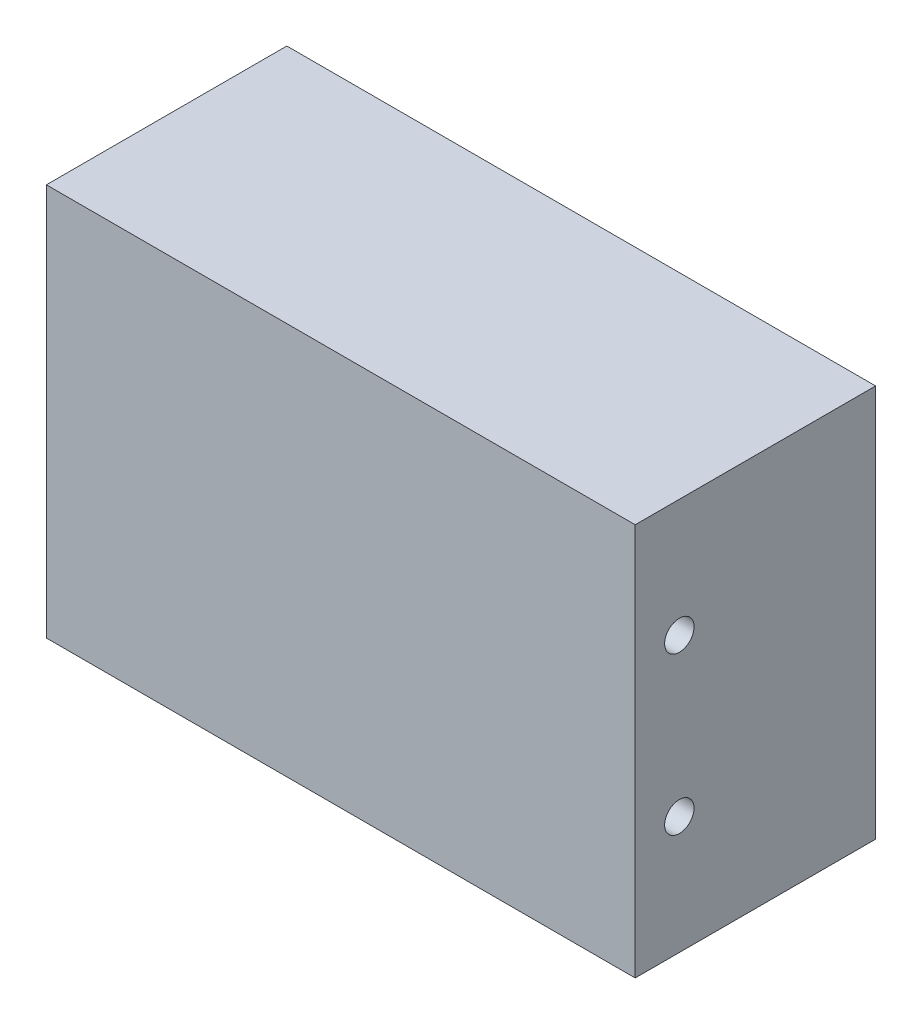
from build123d import *

# Parameters (mm, degrees)
SKETCH_1_W          = 60
SKETCH_1_H          = 24.5
EXTRUDE_1_DEPTH     = 40
SKETCH_2_R          = 1.5
CUT_EXTRUDE_1_DEPTH = 0.5
SKETCH_3_R          = 1.5
CUT_EXTRUDE_2_DEPTH = 3


with BuildPart() as part:
    # 草图1 → 凸台-拉伸1 (new body)
    with BuildSketch(Plane(origin=(0, 0, 0), x_dir=(1, 0, 0), z_dir=(0, 1, 0))):
        Rectangle(SKETCH_1_W, SKETCH_1_H)
    extrude(amount=EXTRUDE_1_DEPTH)

    # 草图2 → 切除-拉伸1 (cut)
    with BuildSketch(Plane(origin=(0, 0, 0), x_dir=(-1, 0, 0), z_dir=(0, -1, 0))):
        with Locations((8, -7.75)):
            Circle(SKETCH_2_R)
        with Locations((-8, -7.75)):
            Circle(SKETCH_2_R)
    extrude(amount=-CUT_EXTRUDE_1_DEPTH, mode=Mode.SUBTRACT)

    # 草图3 → 切除-拉伸2 (cut)
    with BuildSketch(Plane(origin=(30, 0, 0), x_dir=(0, 0, -1), z_dir=(1, 0, 0))):
        with Locations((-7.75, 28)):
            Circle(SKETCH_3_R)
        with Locations((-7.75, 12)):
            Circle(SKETCH_3_R)
    extrude(amount=-CUT_EXTRUDE_2_DEPTH, mode=Mode.SUBTRACT)


solid = part.part
